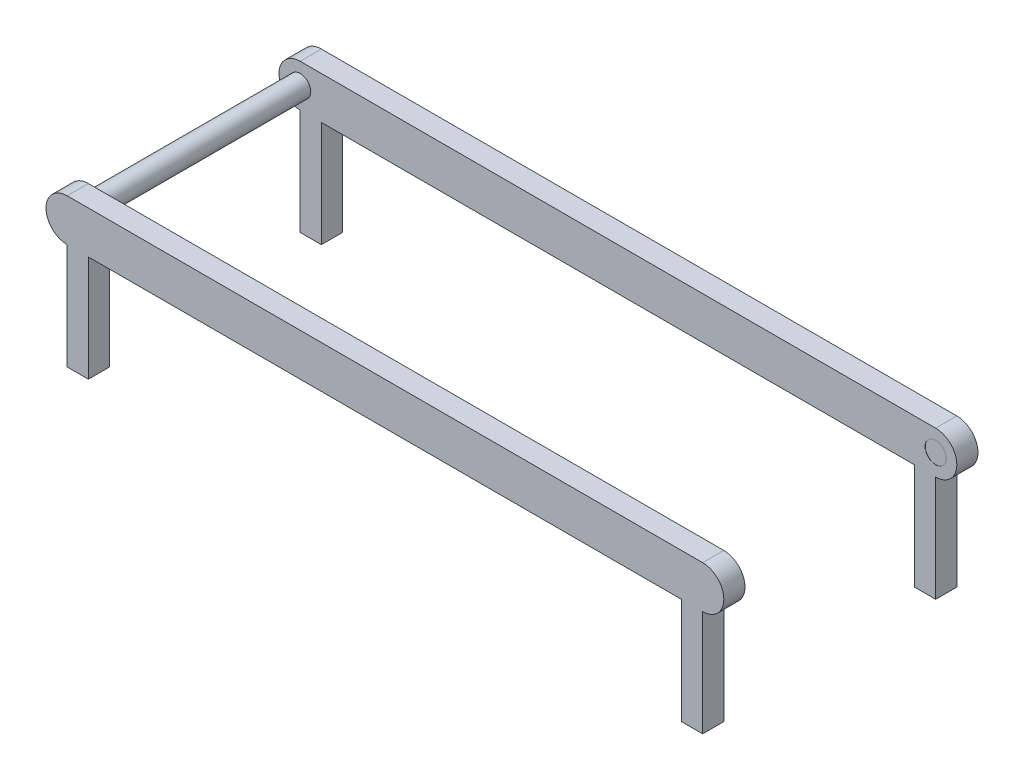
from build123d import *

# Parameters (mm, degrees)
SALIENTE_EXTRUIR1_DEPTH = 10
CROQUIS2_R              = 5
SALIENTE_EXTRUIR2_DEPTH = 100
SALIENTE_EXTRUIR3_DEPTH = 10
CROQUIS4_W              = 10
CROQUIS4_H              = 10
SALIENTE_EXTRUIR4_DEPTH = 50
CROQUIS5_R              = 5
CORTAR_EXTRUIR1_DEPTH   = 0.1


with BuildPart() as part:
    # Croquis1 → Saliente-Extruir1 (new body)
    with BuildSketch(Plane.XY):
        with BuildLine():
            Line((-150, 10), (150, 10))
            ThreePointArc((150, 10), (160, 0), (150, -10))
            Line((150, -10), (-150, -10))
            ThreePointArc((-150, -10), (-160, 0), (-150, 10))
        make_face()
    extrude(amount=SALIENTE_EXTRUIR1_DEPTH)

    # Croquis2 → Saliente-Extruir2 (add)
    with BuildSketch(Plane.XY.offset(10)):
        with Locations((-150, 0)):
            Circle(CROQUIS2_R)
    extrude(amount=SALIENTE_EXTRUIR2_DEPTH)

    # Croquis3 → Saliente-Extruir3 (add)
    with BuildSketch(Plane.XY.offset(110)):
        with BuildLine():
            Line((-150, -10), (150, -10))
            ThreePointArc((150, -10), (160, 0), (150, 10))
            Line((150, 10), (-150, 10))
            ThreePointArc((-150, 10), (-160, 0), (-150, -10))
        make_face()
    extrude(amount=SALIENTE_EXTRUIR3_DEPTH)

    # Croquis4 → Saliente-Extruir4 (add)
    with BuildSketch(Plane.XZ.offset(10)):
        with Locations((-145, 115)):
            Rectangle(CROQUIS4_W, CROQUIS4_H)
        with Locations((145, 115)):
            Rectangle(CROQUIS4_W, CROQUIS4_H)
        with Locations((145, 5)):
            Rectangle(CROQUIS4_W, CROQUIS4_H)
        with Locations((-145, 5)):
            Rectangle(CROQUIS4_W, CROQUIS4_H)
    extrude(amount=SALIENTE_EXTRUIR4_DEPTH)

    # Croquis5 → Cortar-Extruir1 (cut)
    with BuildSketch(Plane.XY.offset(10)):
        with Locations((150, 0)):
            Circle(CROQUIS5_R)
    extrude(amount=-CORTAR_EXTRUIR1_DEPTH, mode=Mode.SUBTRACT)


solid = part.part
